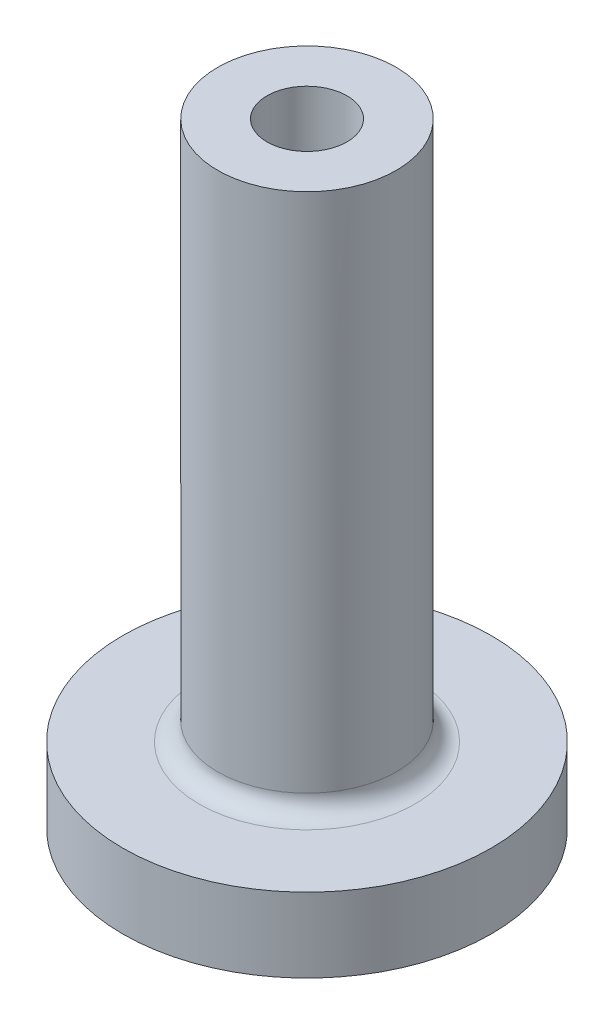
from build123d import *

# Parameters (mm, degrees)
SKETCH1_R           = 9.9
SKETCH1_R_2         = 4.8
SKETCH1_R_3         = 2.15
BOSS_EXTRUDE1_DEPTH = 4
BOSS_EXTRUDE2_START = 4
SKETCH1_3_R         = 4.8
SKETCH1_3_R_2       = 2.15
BOSS_EXTRUDE2_DEPTH = 29
CUT_EXTRUDE1_START  = 33
SKETCH1_4_R         = 2.15
CUT_EXTRUDE1_DEPTH  = 8
FILLET1_R           = 1


with BuildPart() as part:
    # Sketch1 → Boss-Extrude1 (new body)
    with BuildSketch(Plane(origin=(0, 0, 0), x_dir=(1, 0, 0), z_dir=(0, 1, 0))):
        with Locations(Location((0, 0, 0), (0, 0, 270))):
            Circle(SKETCH1_R)
        Circle(SKETCH1_R_2, mode=Mode.SUBTRACT)
        Circle(SKETCH1_R_2)
        Circle(SKETCH1_R_3, mode=Mode.SUBTRACT)
        Circle(SKETCH1_R_3)
    extrude(amount=BOSS_EXTRUDE1_DEPTH)

    # Sketch1_3 → Boss-Extrude2 (add)
    with BuildSketch(Plane(origin=(0, 0, 0), x_dir=(1, 0, 0), z_dir=(0, 1, 0)).offset(BOSS_EXTRUDE2_START)):
        with Locations(Location((0, 0, 0), (0, 0, 90))):
            Circle(SKETCH1_3_R)
        Circle(SKETCH1_3_R_2, mode=Mode.SUBTRACT)
        Circle(SKETCH1_3_R_2)
    extrude(amount=BOSS_EXTRUDE2_DEPTH)

    # Sketch1_4 → Cut-Extrude1 (cut)
    with BuildSketch(Plane(origin=(0, 0, 0), x_dir=(1, 0, 0), z_dir=(0, 1, 0)).offset(CUT_EXTRUDE1_START)):
        with Locations(Location((0, 0, 0), (0, 0, 270))):
            Circle(SKETCH1_4_R)
    extrude(amount=-CUT_EXTRUDE1_DEPTH, mode=Mode.SUBTRACT)

    # Fillet1
    fillet1_edges = [part.edges().sort_by_distance(p)[0] for p in [
        (0, 4, 4.8),
    ]]
    fillet(fillet1_edges, radius=FILLET1_R)


solid = part.part
